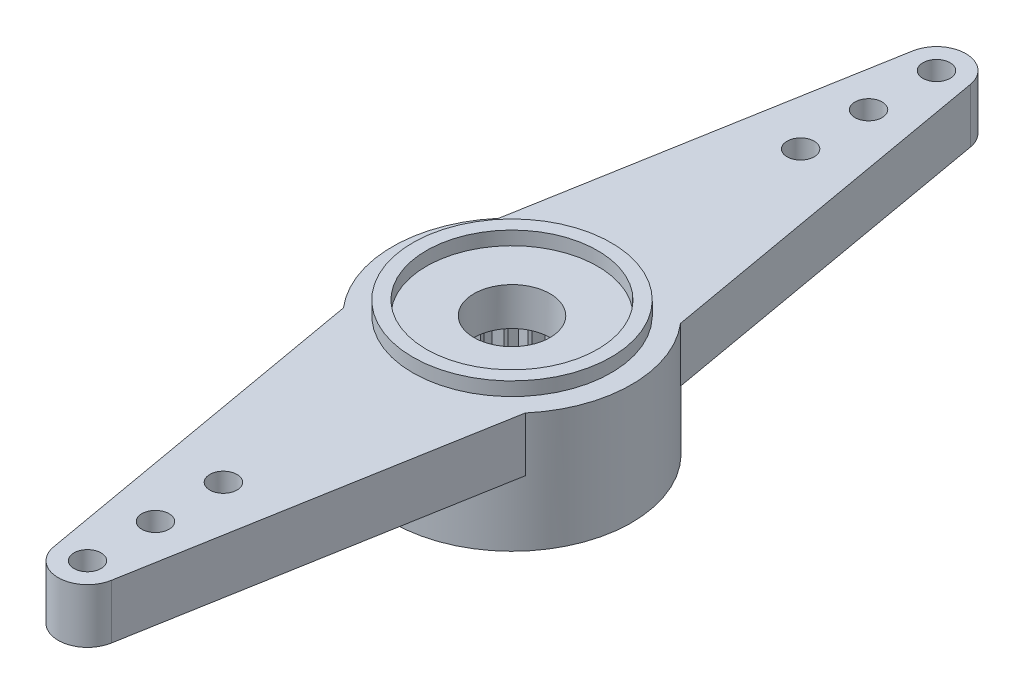
from build123d import *

# Parameters (mm, degrees)
BASES_R                     = 4.4
BASE_DEPTH                  = 4.4
TOPBORES_R                  = 1.4
TOP_BORE_DEPTH              = 8.621023553
HORN_HALF_DEPTH             = 2
HORNATTACHS_R               = 0.5
HORN_ATTACH_DEPTH           = 18.821616088
HA_LP_COUNT                 = 3
HA_LP_PITCH                 = 2.5
HORN_BODIES_COPY_1_SKETCH_R = 0.5
HORN_BODIES_COPY_1_DEPTH    = 18.821616088
HORN_BODIES_COPY_2_SKETCH_R = 0.5
HORN_BODIES_COPY_2_DEPTH    = 18.821616088
TOOTH_DEPTH                 = 3
TOOTH_CP_COUNT              = 26
BOTTOMBORES_R               = 2.6
BOTTOM_BORE_DEPTH           = 3
TOPPOCKETCYLINDERS_R        = 3.65
TOPPOCKETCYLINDERS_R_2      = 3.15
TOP_POCKET_CYLINDER_DEPTH   = 0.5


with BuildPart() as part:
    # BaseS → BASE (new body)
    with BuildSketch(Plane(origin=(0, 0, 0), x_dir=(1, 0, 0), z_dir=(0, 1, 0))):
        with Locations(Location((0, 0, 0), (0, 0, 270))):
            Circle(BASES_R)
    extrude(amount=BASE_DEPTH)

    # TopBoreS → TOP BORE (cut, through all)
    with BuildSketch(Plane(origin=(0, 4.4, 0), x_dir=(1, 0, 0), z_dir=(0, 1, 0))):
        with Locations(Location((0, 0, 0), (0, 0, 270))):
            Circle(TOPBORES_R)
    extrude(amount=-TOP_BORE_DEPTH, mode=Mode.SUBTRACT)

    # HornHalfS → HORN HALF (add)
    with BuildSketch(Plane(origin=(0, 4.4, 0), x_dir=(1, 0, 0), z_dir=(0, 1, 0))):
        with BuildLine():
            Line((-1.063592373, 15.807540032), (-3.347342764, 2.855747962))
            ThreePointArc((-3.347342764, 2.855747962), (0, 4.4), (3.347342764, 2.855747962))
            Line((3.347342764, 2.855747962), (1.063592373, 15.807540032))
            ThreePointArc((1.063592373, 15.807540032), (0, 16.7), (-1.063592373, 15.807540032))
        make_face()
    horn_half = extrude(amount=-HORN_HALF_DEPTH)

    # HornAttachS → HORN ATTACH (cut, through all)
    with BuildSketch(Plane(origin=(0, 4.4, 0), x_dir=(1, 0, 0), z_dir=(0, 1, 0))):
        with Locations(Location((0, 15.62, 0), (0, 0, 270))):
            Circle(HORNATTACHS_R)
    horn_attach = extrude(amount=-HORN_ATTACH_DEPTH, mode=Mode.SUBTRACT)

    # HA LP: HORN ATTACH ×3
    with Locations(*[(0, 0, i * HA_LP_PITCH) for i in range(1, HA_LP_COUNT)]):
        add(horn_attach, mode=Mode.SUBTRACT)

    # HORN BODIES: HORN HALF, HORN ATTACH across plane
    add(horn_half.mirror(Plane.XY))
    add(horn_attach.mirror(Plane.XY), mode=Mode.SUBTRACT)

    # HORN BODIES copy 1 sketch → HORN BODIES copy 1 (cut, through all)
    with BuildSketch(Plane(origin=(0, 4.4, -2.5), x_dir=(1, 0, 0), z_dir=(0, 1, 0))):
        with Locations((0, -15.62)):
            Circle(HORN_BODIES_COPY_1_SKETCH_R)
    extrude(amount=-HORN_BODIES_COPY_1_DEPTH, mode=Mode.SUBTRACT)

    # HORN BODIES copy 2 sketch → HORN BODIES copy 2 (cut, through all)
    with BuildSketch(Plane(origin=(0, 4.4, -5), x_dir=(1, 0, 0), z_dir=(0, 1, 0))):
        with Locations((0, -15.62)):
            Circle(HORN_BODIES_COPY_2_SKETCH_R)
    extrude(amount=-HORN_BODIES_COPY_2_DEPTH, mode=Mode.SUBTRACT)

    # ToothS → TOOTH (cut)
    with BuildSketch(Plane.XZ):
        with BuildLine():
            Line((0, -2.9), (0.262912611, -2.586672952))
            ThreePointArc((0.262912611, -2.586672952), (0, -2.6), (-0.262912611, -2.586672952))
            Line((-0.262912611, -2.586672952), (0, -2.9))
        make_face()
    tooth = extrude(amount=-TOOTH_DEPTH, mode=Mode.SUBTRACT)

    # TOOTH CP: TOOTH ×26 about axis
    tooth_cp_axis = Axis((0, 0, 0), (0, 1, 0))
    for i in range(1, TOOTH_CP_COUNT):
        add(tooth.rotate(tooth_cp_axis, i * 360 / TOOTH_CP_COUNT), mode=Mode.SUBTRACT)

    # BottomBoreS → BOTTOM BORE (cut)
    with BuildSketch(Plane(origin=(0, 0, 0), x_dir=(-1, 0, 0), z_dir=(0, -1, 0))):
        Circle(BOTTOMBORES_R)
    extrude(amount=-BOTTOM_BORE_DEPTH, mode=Mode.SUBTRACT)

    # TopPocketCylinderS → TOP POCKET CYLINDER (add)
    with BuildSketch(Plane(origin=(0, 4.4, 0), x_dir=(1, 0, 0), z_dir=(0, 1, 0))):
        with Locations(Location((0, 0, 0), (0, 0, 270))):
            Circle(TOPPOCKETCYLINDERS_R)
        with Locations(Location((0, 0, 0), (0, 0, 270))):
            Circle(TOPPOCKETCYLINDERS_R_2, mode=Mode.SUBTRACT)
    extrude(amount=TOP_POCKET_CYLINDER_DEPTH)


solid = part.part
